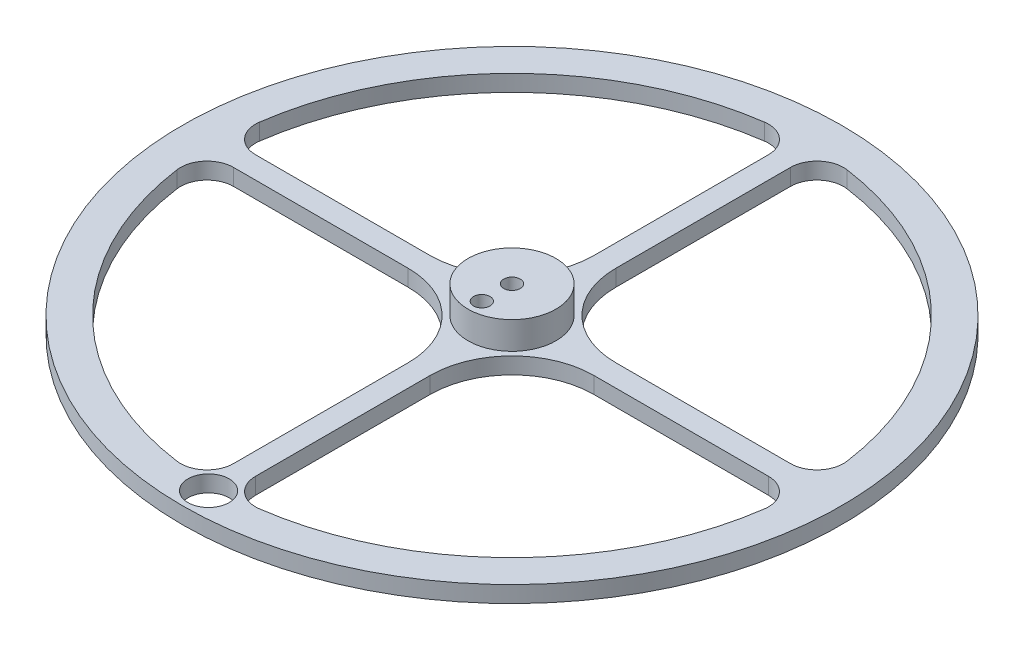
from build123d import *

# Parameters (mm, degrees)
SKETCH1_R           = 60
BOSS_EXTRUDE1_DEPTH = 3
SKETCH1_3_R         = 8
BOSS_EXTRUDE2_DEPTH = 5
CUT_EXTRUDE1_REACH  = 10
SKETCH2_R           = 1.5
CUT_EXTRUDE2_REACH  = 5
SKETCH3_R           = 3.75
SKETCH4_R           = 1.5
CUT_EXTRUDE3_DEPTH  = 5


with BuildPart() as part:
    # Sketch1 → Boss-Extrude1 (new body)
    with BuildSketch(Plane(origin=(0, 0, 0), x_dir=(1, 0, 0), z_dir=(0, 1, 0))):
        Circle(SKETCH1_R)
        with BuildLine():
            ThreePointArc((7.5, -53.47663041), (3.660460389, -52.338407931), (2.000000204, -48.694167705))
            Line((2.000000204, -48.694167705), (2.000000204, -16.899494443))
            ThreePointArc((2.000000204, -16.899494443), (6.363961031, -6.363961031), (16.899494443, -2.000000204))
            Line((16.899494443, -2.000000204), (48.694167705, -2.000000204))
            ThreePointArc((48.694167705, -2.000000204), (52.338407931, -3.660460389), (53.47663041, -7.5))
            ThreePointArc((53.47663041, -7.5), (38.183766184, -38.183766184), (7.5, -53.47663041))
        make_face(mode=Mode.SUBTRACT)
        with BuildLine():
            ThreePointArc((53.47663041, 7.5), (52.338407931, 3.660460389), (48.694167705, 2.000000204))
            Line((48.694167705, 2.000000204), (16.899494443, 2.000000204))
            ThreePointArc((16.899494443, 2.000000204), (6.363961031, 6.363961031), (2.000000204, 16.899494443))
            Line((2.000000204, 16.899494443), (2.000000204, 48.694167705))
            ThreePointArc((2.000000204, 48.694167705), (3.660460389, 52.338407931), (7.5, 53.47663041))
            ThreePointArc((7.5, 53.47663041), (38.183766184, 38.183766184), (53.47663041, 7.5))
        make_face(mode=Mode.SUBTRACT)
        with BuildLine():
            ThreePointArc((-7.5, 53.47663041), (-3.660460389, 52.338407931), (-2.000000204, 48.694167705))
            Line((-2.000000204, 48.694167705), (-2.000000204, 16.899494443))
            ThreePointArc((-2.000000204, 16.899494443), (-6.363961031, 6.363961031), (-16.899494443, 2.000000204))
            Line((-16.899494443, 2.000000204), (-48.694167705, 2.000000204))
            ThreePointArc((-48.694167705, 2.000000204), (-52.338407931, 3.660460389), (-53.47663041, 7.5))
            ThreePointArc((-53.47663041, 7.5), (-38.183766184, 38.183766184), (-7.5, 53.47663041))
        make_face(mode=Mode.SUBTRACT)
        with BuildLine():
            ThreePointArc((-53.47663041, -7.5), (-52.338407931, -3.660460389), (-48.694167705, -2.000000204))
            Line((-48.694167705, -2.000000204), (-16.899494443, -2.000000204))
            ThreePointArc((-16.899494443, -2.000000204), (-6.363961031, -6.363961031), (-2.000000204, -16.899494443))
            Line((-2.000000204, -16.899494443), (-2.000000204, -48.694167705))
            ThreePointArc((-2.000000204, -48.694167705), (-3.660460389, -52.338407931), (-7.5, -53.47663041))
            ThreePointArc((-7.5, -53.47663041), (-38.183766184, -38.183766184), (-53.47663041, -7.5))
        make_face(mode=Mode.SUBTRACT)
    extrude(amount=-BOSS_EXTRUDE1_DEPTH)

    # Sketch1_3 → Boss-Extrude2 (add)
    with BuildSketch(Plane(origin=(0, 0, 0), x_dir=(1, 0, 0), z_dir=(0, 1, 0))):
        Circle(SKETCH1_3_R)
    extrude(amount=BOSS_EXTRUDE2_DEPTH)

    # Sketch2 → Cut-Extrude1 (cut, up to next)
    with BuildSketch(Plane(origin=(0, 5, 0), x_dir=(1, 0, 0), z_dir=(0, 1, 0)), mode=Mode.PRIVATE) as cut_extrude1_sk1:
        Circle(SKETCH2_R)
    cut_extrude1_tool1 = extrude(cut_extrude1_sk1.sketch, amount=-CUT_EXTRUDE1_REACH, mode=Mode.PRIVATE) & part.part
    add(cut_extrude1_tool1.solids().sort_by_distance((0, 5, 0))[0], mode=Mode.SUBTRACT)

    # Sketch3 → Cut-Extrude2 (cut, up to next)
    with BuildSketch(Plane(origin=(0, 0, 0), x_dir=(1, 0, 0), z_dir=(0, 1, 0)), mode=Mode.PRIVATE) as cut_extrude2_sk1:
        with Locations((0, -55.25)):
            Circle(SKETCH3_R)
    cut_extrude2_tool1 = extrude(cut_extrude2_sk1.sketch, amount=-CUT_EXTRUDE2_REACH, mode=Mode.PRIVATE) & part.part
    add(cut_extrude2_tool1.solids().sort_by_distance((0, 0, 55.25))[0], mode=Mode.SUBTRACT)

    # Sketch4 → Cut-Extrude3 (cut)
    with BuildSketch(Plane(origin=(0, 5, 0), x_dir=(1, 0, 0), z_dir=(0, 1, 0))):
        with Locations((0, -5.5)):
            Circle(SKETCH4_R)
    extrude(amount=-CUT_EXTRUDE3_DEPTH, mode=Mode.SUBTRACT)


solid = part.part
